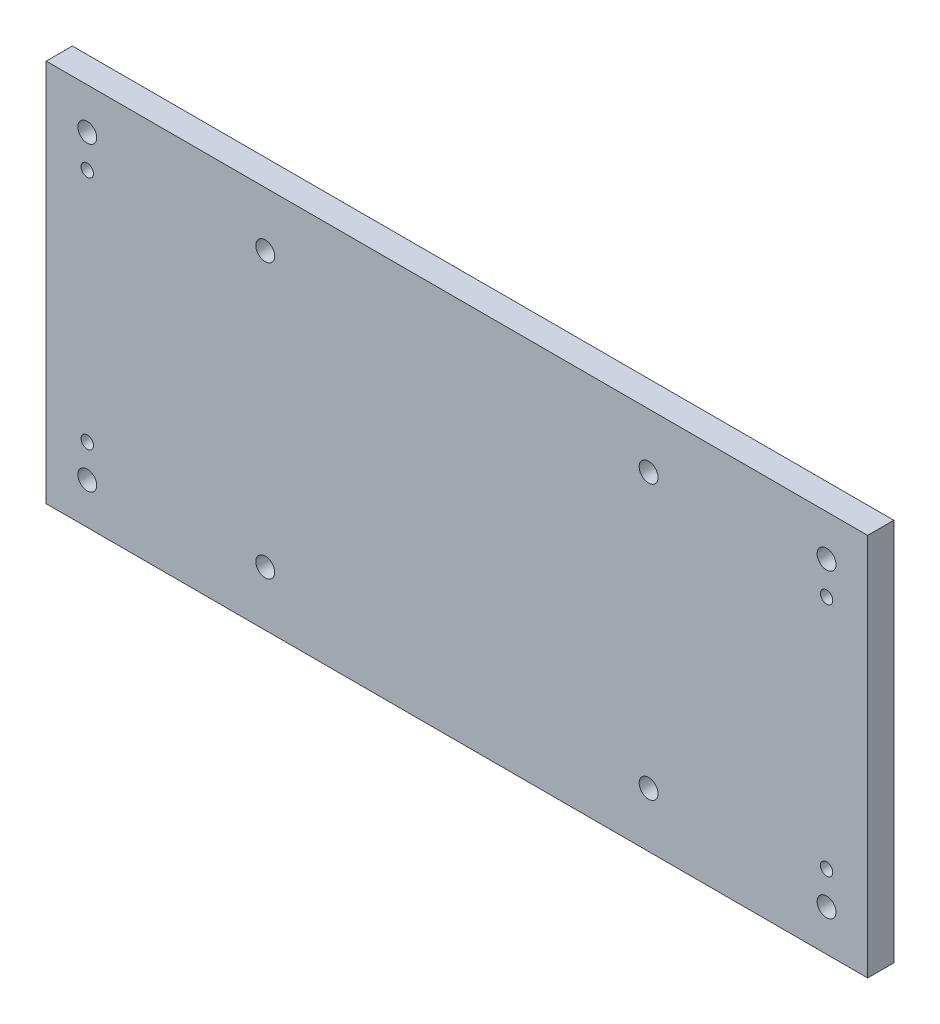
from build123d import *

# Parameters (mm, degrees)
SKETCH1_W             = 150
SKETCH1_H             = 70
SKETCH1_R             = 1.725
SKETCH1_R_2           = 1.13
BOSS_EXTRUDE1_DEPTH   = 4.7752
F_4_40_TAPPED_HOLE1_D = 2.2606


with BuildPart() as part:
    # Sketch1 → Boss-Extrude1 (new body)
    with BuildSketch(Plane.XY):
        with Locations((75, -35)):
            Rectangle(SKETCH1_W, SKETCH1_H)
        with Locations((7.5, -7.5)):
            Circle(SKETCH1_R, mode=Mode.SUBTRACT)
        with Locations((142.5, -7.5)):
            Circle(SKETCH1_R, mode=Mode.SUBTRACT)
        with Locations((142.5, -62.5)):
            Circle(SKETCH1_R, mode=Mode.SUBTRACT)
        with Locations((7.5, -62.5)):
            Circle(SKETCH1_R, mode=Mode.SUBTRACT)
        with Locations((7.5, -13.5)):
            Circle(SKETCH1_R_2, mode=Mode.SUBTRACT)
        with Locations((142.5, -13.5)):
            Circle(SKETCH1_R_2, mode=Mode.SUBTRACT)
        with Locations((142.5, -56.5)):
            Circle(SKETCH1_R_2, mode=Mode.SUBTRACT)
        with Locations((7.5, -56.5)):
            Circle(SKETCH1_R_2, mode=Mode.SUBTRACT)
        with Locations((40, -10)):
            Circle(SKETCH1_R, mode=Mode.SUBTRACT)
        with Locations((40, -60)):
            Circle(SKETCH1_R, mode=Mode.SUBTRACT)
        with Locations((110, -10)):
            Circle(SKETCH1_R, mode=Mode.SUBTRACT)
        with Locations((110, -60)):
            Circle(SKETCH1_R, mode=Mode.SUBTRACT)
    extrude(amount=BOSS_EXTRUDE1_DEPTH)

    # #4-40 Tapped Hole1 (through all)
    with Locations(Plane(origin=(7.5, -13.5, 4.7752), x_dir=(1, 0, 0), z_dir=(0, 0, 1))):
        with Locations((0, 0), (0, -43), (135, -43), (135, 0)):
            Hole(F_4_40_TAPPED_HOLE1_D / 2)


solid = part.part
